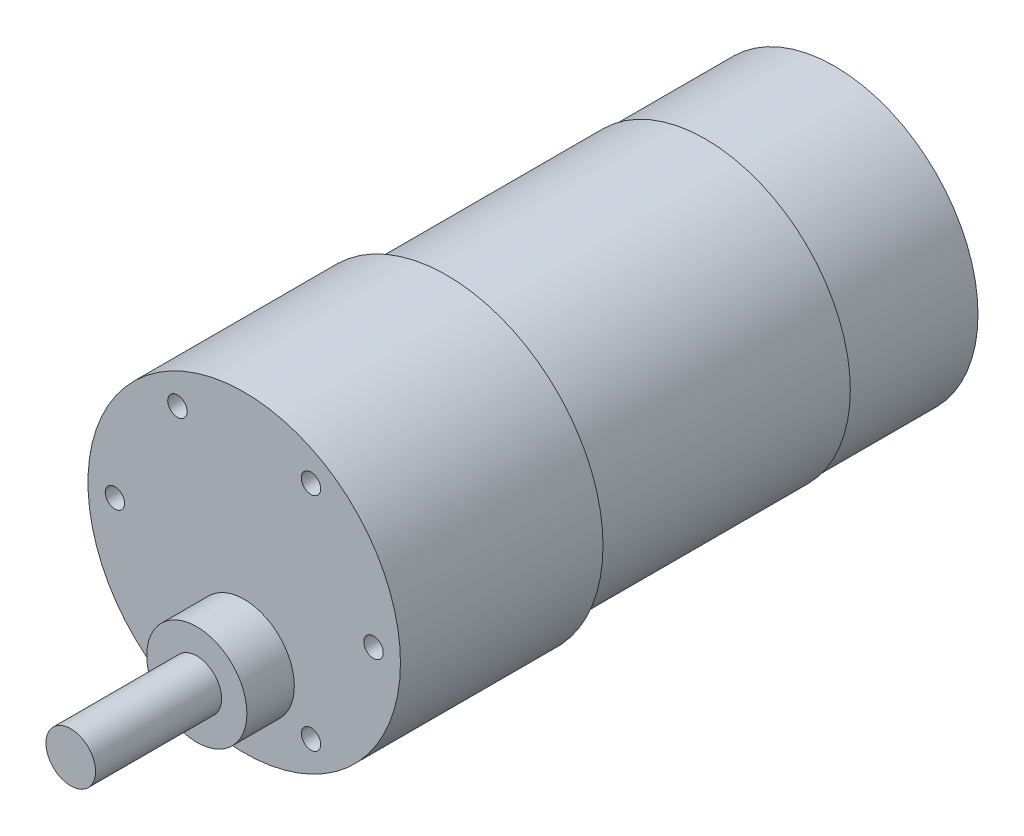
from build123d import *

# Parameters (mm, degrees)
SKETCH1_R           = 18.415
BOSS_EXTRUDE1_DEPTH = 23.876
SKETCH2_R           = 5.9055
BOSS_EXTRUDE2_DEPTH = 5.588
SKETCH3_R           = 2.921
BOSS_EXTRUDE3_DEPTH = 14.859
SKETCH4_R           = 17.0815
BOSS_EXTRUDE4_DEPTH = 30.48
SKETCH5_R           = 16.891
BOSS_EXTRUDE5_DEPTH = 15.24
SKETCH6_R           = 1.143
CUT_EXTRUDE1_DEPTH  = 15.24
CIRPATTERN1_COUNT   = 2
SKETCH8_W           = 14.224
SKETCH8_H           = 3.683
CUT_EXTRUDE2_DEPTH  = 2.54


with BuildPart() as part:
    # Sketch1 → Boss-Extrude1 (new body)
    with BuildSketch(Plane.XY):
        Circle(SKETCH1_R)
    extrude(amount=-BOSS_EXTRUDE1_DEPTH)

    # Sketch2 → Boss-Extrude2 (add)
    with BuildSketch(Plane.XY):
        with Locations((0, -8.636)):
            Circle(SKETCH2_R)
    extrude(amount=BOSS_EXTRUDE2_DEPTH)

    # Sketch3 → Boss-Extrude3 (add)
    with BuildSketch(Plane.XY.offset(5.588)):
        with Locations((0, -8.636)):
            Circle(SKETCH3_R)
    extrude(amount=BOSS_EXTRUDE3_DEPTH)

    # Sketch4 → Boss-Extrude4 (add)
    with BuildSketch(Plane(origin=(0, 0, -23.876), x_dir=(-1, 0, 0), z_dir=(0, 0, -1))):
        Circle(SKETCH4_R)
    extrude(amount=BOSS_EXTRUDE4_DEPTH)

    # Sketch5 → Boss-Extrude5 (add)
    with BuildSketch(Plane(origin=(0, 0, -54.356), x_dir=(-1, 0, 0), z_dir=(0, 0, -1))):
        Circle(SKETCH5_R)
    extrude(amount=BOSS_EXTRUDE5_DEPTH)

    # Sketch6 → Cut-Extrude1 (cut)
    with BuildSketch(Plane.XY):
        with Locations((7.871883333, -13.049561402)):
            Circle(SKETCH6_R)
        with Locations((15.24, 0)):
            Circle(SKETCH6_R)
        with Locations((7.871883333, 13.049561402)):
            Circle(SKETCH6_R)
    cut_extrude1 = extrude(amount=-CUT_EXTRUDE1_DEPTH, mode=Mode.SUBTRACT)

    # CirPattern1: Cut-Extrude1 ×2 about axis
    cirpattern1_axis = Axis((0, 0, 0), (0, 0, 1))
    for i in range(1, CIRPATTERN1_COUNT):
        add(cut_extrude1.rotate(cirpattern1_axis, i * 360 / CIRPATTERN1_COUNT), mode=Mode.SUBTRACT)

    # Sketch8 → Cut-Extrude2 (cut)
    with BuildSketch(Plane(origin=(0, -16.891, 0), x_dir=(-1, 0, 0), z_dir=(0, -1, 0))):
        with Locations((0, 58.7375)):
            Rectangle(SKETCH8_W, SKETCH8_H)
    extrude(amount=-CUT_EXTRUDE2_DEPTH, mode=Mode.SUBTRACT)


solid = part.part
